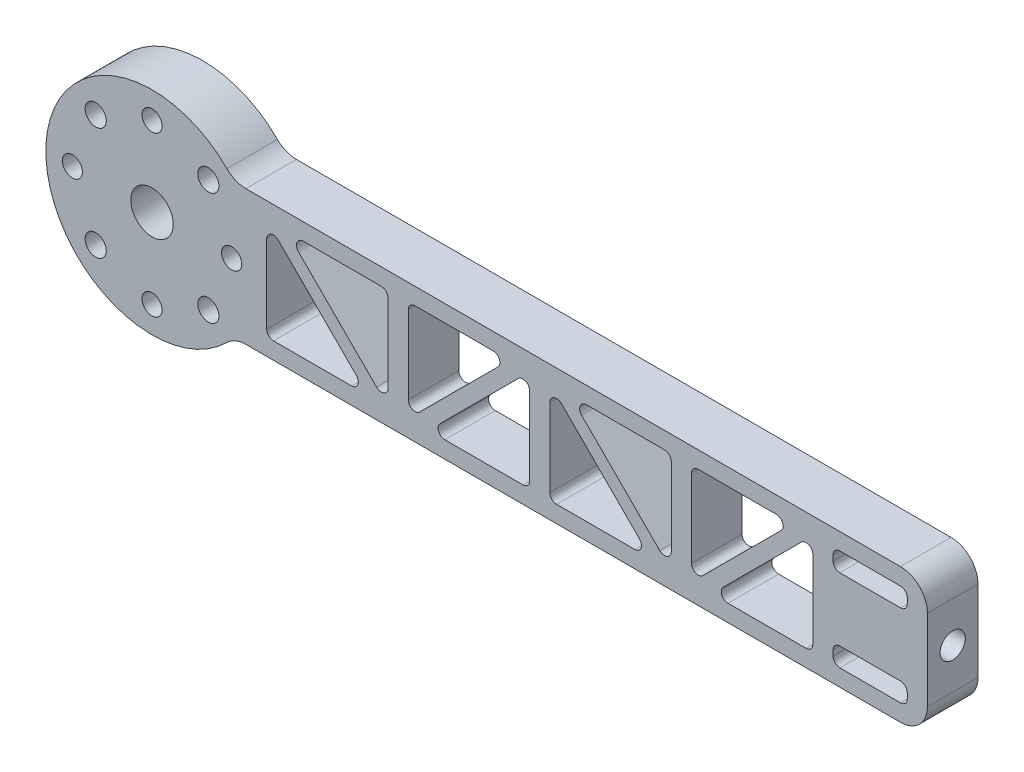
from build123d import *

# Parameters (mm, degrees)
SKETCH1_R           = 4
BOSS_EXTRUDE1_DEPTH = 9.525
SKETCH3_R           = 1.89865
SKETCH3_R_2         = 1.9939
CUT_EXTRUDE2_DEPTH  = 10.525
SKETCH19_W          = 13.97
SKETCH19_H          = 3.556
CUT_EXTRUDE4_DEPTH  = 10.525
CUT_EXTRUDE5_REACH  = 168.05
SKETCH20_R          = 2.38125
FILLET5_R           = 5.08
FILLET6_R           = 5.08
FILLET7_R           = 1.27


with BuildPart() as part:
    # Sketch1 → Boss-Extrude1 (new body)
    with BuildSketch(Plane.XY):
        with BuildLine():
            Line((73.025, 12.7), (73.025, -12.7))
            Line((73.025, -12.7), (-57.574757283, -12.7))
            ThreePointArc((-57.574757283, -12.7), (-64.480996255, -18.08314132), (-73.025, -20))
            ThreePointArc((-73.025, -20), (-93.025, 0), (-73.025, 20))
            ThreePointArc((-73.025, 20), (-64.480996255, 18.08314132), (-57.574757283, 12.7))
            Line((-57.574757283, 12.7), (73.025, 12.7))
        make_face()
        with Locations((-73.025, 0)):
            Circle(SKETCH1_R, mode=Mode.SUBTRACT)
    extrude(amount=BOSS_EXTRUDE1_DEPTH)

    # Sketch3 → Cut-Extrude2 (cut, through all)
    with BuildSketch(Plane.XY):
        with Locations((-73.025, 15)):
            Circle(SKETCH3_R)
        with Locations((-58.025, 0)):
            Circle(SKETCH3_R)
        with Locations((-73.025, -15)):
            Circle(SKETCH3_R)
        with Locations((-88.025, 0)):
            Circle(SKETCH3_R)
        with Locations((-83.631601718, -10.606601718)):
            Circle(SKETCH3_R_2)
        with Locations((-83.631601718, 10.606601718)):
            Circle(SKETCH3_R_2)
        with Locations((-62.418398282, 10.606601718)):
            Circle(SKETCH3_R_2)
        with Locations((-62.418398282, -10.606601718)):
            Circle(SKETCH3_R_2)
    extrude(amount=CUT_EXTRUDE2_DEPTH, mode=Mode.SUBTRACT)

    # Sketch19 → Cut-Extrude4 (cut, through all)
    with BuildSketch(Plane.XY.offset(9.525)):
        Polygon((-51.4245, -9.525), (-32.3745, -9.525), (-51.4245, 9.525), align=None)
        with Locations((62.2405, 7.747)):
            Rectangle(SKETCH19_W, SKETCH19_H)
        Polygon((-47.6145, 9.525), (-28.5645, -9.525), (-28.5645, 9.525), align=None)
        Polygon((-1.8945, -9.525), (-20.9445, -9.525), (-1.8945, 9.525), align=None)
        Polygon((-24.7545, -9.525), (-24.7545, 9.525), (-5.7045, 9.525), align=None)
        Polygon((1.9155, -9.525), (1.9155, 9.525), (20.9655, -9.525), align=None)
        Polygon((5.7255, 9.525), (24.7755, -9.525), (24.7755, 9.525), align=None)
        Polygon((28.5855, 9.525), (47.6355, 9.525), (28.5855, -9.525), align=None)
        Polygon((51.4455, -9.525), (32.3955, -9.525), (51.4455, 9.525), align=None)
        with Locations((62.2405, -7.747)):
            Rectangle(SKETCH19_W, SKETCH19_H)
    extrude(amount=-CUT_EXTRUDE4_DEPTH, mode=Mode.SUBTRACT)

    # Sketch20 → Cut-Extrude5 (cut, up to next)
    with BuildSketch(Plane(origin=(73.025, 0, 0), x_dir=(0, 0, -1), z_dir=(1, 0, 0)), mode=Mode.PRIVATE) as cut_extrude5_sk1:
        with Locations((-4.7625, 0)):
            Circle(SKETCH20_R)
    cut_extrude5_tool1 = extrude(cut_extrude5_sk1.sketch, amount=-CUT_EXTRUDE5_REACH, mode=Mode.PRIVATE) & part.part
    add(cut_extrude5_tool1.solids().sort_by_distance((73.025, 0, 4.7625))[0], mode=Mode.SUBTRACT)

    # Fillet5
    fillet5_edges = [part.edges().sort_by_distance(p)[0] for p in [
        (73.025, 12.7, 4.7625),
        (73.025, -12.7, 4.7625),
    ]]
    fillet(fillet5_edges, radius=FILLET5_R)

    # Fillet6
    fillet6_edges = [part.edges().sort_by_distance(p)[0] for p in [
        (-57.574757283, 12.7, 4.7625),
        (-57.574757283, -12.7, 4.7625),
    ]]
    fillet(fillet6_edges, radius=FILLET6_R)

    # Fillet7
    fillet7_edges = [part.edges().sort_by_distance(p)[0] for p in [
        (51.4455, 9.525, 4.7625),
        (51.4455, -9.525, 4.7625),
        (32.3955, -9.525, 4.7625),
        (69.2255, -9.525, 4.7625),
        (55.2555, -9.525, 4.7625),
        (55.2555, -5.969, 4.7625),
        (69.2255, -5.969, 4.7625),
        (-51.4245, 9.525, 4.7625),
        (-32.3745, -9.525, 4.7625),
        (-51.4245, -9.525, 4.7625),
        (20.9655, -9.525, 4.7625),
        (1.9155, -9.525, 4.7625),
        (1.9155, 9.525, 4.7625),
        (-5.7045, 9.525, 4.7625),
        (-24.7545, -9.525, 4.7625),
        (-24.7545, 9.525, 4.7625),
        (-1.8945, 9.525, 4.7625),
        (-1.8945, -9.525, 4.7625),
        (-20.9445, -9.525, 4.7625),
        (55.2555, 5.969, 4.7625),
        (55.2555, 9.525, 4.7625),
        (69.2255, 9.525, 4.7625),
        (69.2255, 5.969, 4.7625),
        (-47.6145, 9.525, 4.7625),
        (-28.5645, 9.525, 4.7625),
        (-28.5645, -9.525, 4.7625),
        (5.7255, 9.525, 4.7625),
        (24.7755, 9.525, 4.7625),
        (24.7755, -9.525, 4.7625),
        (28.5855, -9.525, 4.7625),
        (28.5855, 9.525, 4.7625),
        (47.6355, 9.525, 4.7625),
    ]]
    fillet(fillet7_edges, radius=FILLET7_R)


solid = part.part
